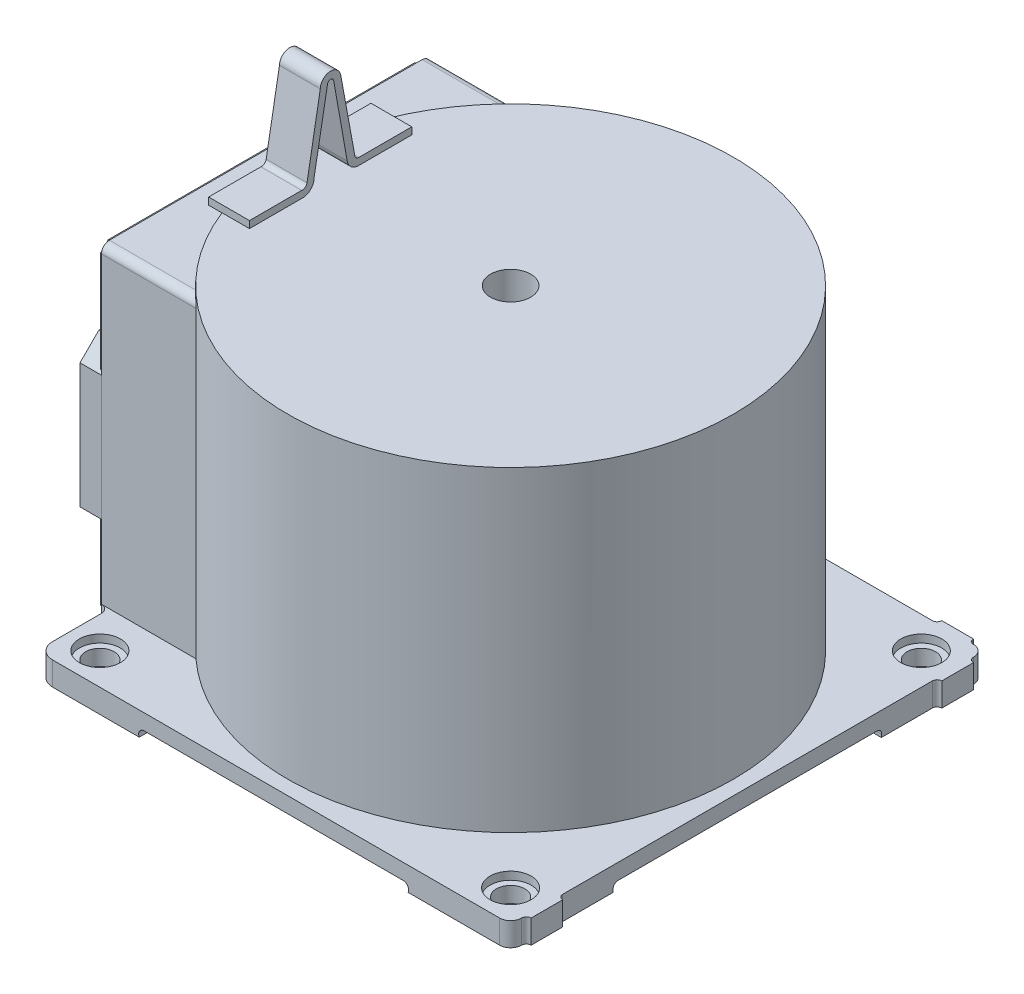
from build123d import *

# Parameters (mm, degrees)
BASE_EXTRUDE_DEPTH  = 14.9225
CUT_EXTRUDE1_DEPTH  = 304
CUT_EXTRUDE2_DEPTH  = 306
SKETCH7_R           = 13
CUT_EXTRUDE3_DEPTH  = 5
SKETCH8_R           = 9
CUT_EXTRUDE4_DEPTH  = 10.9225001
SKETCH9_R           = 141
BOSS_EXTRUDE1_DEPTH = 200.152
BOSS_EXTRUDE2_REACH = 310
BOSS_EXTRUDE3_DEPTH = 14.097
BOSS_EXTRUDE4_DEPTH = 2.667
BOSS_EXTRUDE5_DEPTH = 34.0995
SKETCH14_W          = 65
SKETCH14_H          = 35
SKETCH14_R          = 1.75
CUT_EXTRUDE5_DEPTH  = 17.272
BOSS_EXTRUDE6_DEPTH = 25.8445
SKETCH16_R          = 12.7
CUT_EXTRUDE6_DEPTH  = 216.0745001


with BuildPart() as part:
    # Sketch3 → Base-Extrude (new body)
    with BuildSketch(Plane(origin=(0, 0, 0), x_dir=(1, 0, 0), z_dir=(0, 1, 0))):
        with BuildLine():
            Line((140, 153), (120, 153))
            ThreePointArc((120, 153), (119.121320344, 150.878679656), (117, 150))
            Line((117, 150), (-117, 150))
            ThreePointArc((-117, 150), (-119.121320344, 150.878679656), (-120, 153))
            Line((-120, 153), (-140, 153))
            ThreePointArc((-140, 153), (-140.878679675, 150.878679658), (-143.000000024, 150))
            ThreePointArc((-143.000000024, 150), (-147.949747477, 147.94974746), (-150, 143))
            Line((-150, 143), (-150, 109))
            ThreePointArc((-150, 109), (-151.464466094, 105.464466094), (-155, 104))
            Line((-155, 104), (-155, -104))
            ThreePointArc((-155, -104), (-151.464466083, -105.464466088), (-149.999999983, -109))
            Line((-149.999999983, -109), (-149.999999983, -140))
            ThreePointArc((-149.999999983, -140), (-147.071067794, -147.071067812), (-139.999999983, -150))
            Line((-139.999999983, -150), (143.000000017, -150))
            ThreePointArc((143.000000017, -150), (147.949747486, -147.949747468), (150.000000017, -143))
            ThreePointArc((150.000000017, -143), (150.87867967, -140.87867966), (153.000000007, -140))
            Line((153.000000007, -140), (153.000000007, -120))
            ThreePointArc((153.000000007, -120), (150.878679659, -119.121320346), (150, -117))
            Line((150, -117), (150, 117))
            ThreePointArc((150, 117), (150.878679653, 119.12132034), (152.99999999, 120))
            Line((152.99999999, 120), (152.99999999, 140))
            ThreePointArc((152.99999999, 140), (150.87867965, 140.878679657), (150, 143))
            ThreePointArc((150, 143), (147.949747475, 147.949747475), (143, 150))
            ThreePointArc((143, 150), (140.878679653, 150.878679653), (140, 153))
        make_face()
    extrude(amount=BASE_EXTRUDE_DEPTH)

    # Sketch4 → Cut-Extrude1 (cut, through all)
    with BuildSketch(Plane.XY.offset(150)):
        with BuildLine():
            Line((82.000019446, 5), (-81.999980554, 5))
            ThreePointArc((-81.999980554, 5), (-84.938867255, 3.361421394), (-85.09, 0))
            Line((-85.09, 0), (-85.09, -16.51))
            Line((-85.09, -16.51), (85.09, -16.51))
            Line((85.09, -16.51), (85.09, 0))
            ThreePointArc((85.09, 0), (84.938895925, 3.361416251), (82.000019446, 5))
        make_face()
    extrude(amount=-CUT_EXTRUDE1_DEPTH, mode=Mode.SUBTRACT)

    # Sketch6 → Cut-Extrude2 (cut, through all)
    with BuildSketch(Plane(origin=(150, 0, 0), x_dir=(0, 0, -1), z_dir=(1, 0, 0))):
        with BuildLine():
            Line((82.00048999, 5.000122), (-82.00048001, 5.000122))
            ThreePointArc((-82.00048001, 5.000122), (-84.422201707, 3.861415448), (-85.09, 1.27))
            Line((-85.09, 1.27), (-85.09, -4.254424912))
            Line((-85.09, -4.254424912), (84.688287031, -4.254424912))
            Line((84.688287031, -4.254424912), (84.688287031, 1.855594301))
            ThreePointArc((84.688287031, 1.855594301), (84.068841228, 4.047086874), (82.00048999, 5.000122))
        make_face()
    extrude(amount=-CUT_EXTRUDE2_DEPTH, mode=Mode.SUBTRACT)

    # Sketch7 → Cut-Extrude3 (cut)
    with BuildSketch(Plane(origin=(0, 14.9225, 0), x_dir=(-1, 0, 0), z_dir=(0, 1, 0))):
        with Locations(Location((-130, 130, 0), (0, 0, 90))):  # turned: the seam where the file's is
            Circle(SKETCH7_R)
        with Locations(Location((-130, -130, 0), (0, 0, 90))):  # turned: the seam where the file's is
            Circle(SKETCH7_R)
        with Locations(Location((130, -130, 0), (0, 0, 90))):  # turned: the seam where the file's is
            Circle(SKETCH7_R)
        with Locations(Location((130, 130, 0), (0, 0, 90))):  # turned: the seam where the file's is
            Circle(SKETCH7_R)
    extrude(amount=-CUT_EXTRUDE3_DEPTH, mode=Mode.SUBTRACT)

    # Sketch8 → Cut-Extrude4 (cut, through all)
    with BuildSketch(Plane(origin=(0, 9.9225, 0), x_dir=(-1, 0, 0), z_dir=(0, 1, 0))):
        with Locations(Location((-130, -130, 0), (0, 0, 90))):  # turned: the seam where the file's is
            Circle(SKETCH8_R)
        with Locations(Location((130, -130, 0), (0, 0, 90))):  # turned: the seam where the file's is
            Circle(SKETCH8_R)
        with Locations(Location((130, 130, 0), (0, 0, 90))):  # turned: the seam where the file's is
            Circle(SKETCH8_R)
        with Locations(Location((-130, 130, 0), (0, 0, 90))):  # turned: the seam where the file's is
            Circle(SKETCH8_R)
    extrude(amount=-CUT_EXTRUDE4_DEPTH, mode=Mode.SUBTRACT)

    # Sketch9 → Boss-Extrude1 (add)
    with BuildSketch(Plane(origin=(0, 14.9225, 0), x_dir=(-1, 0, 0), z_dir=(0, 1, 0))):
        with Locations(Location((0, 0, 0), (0, 0, 312.473591148))):  # turned: the seam where the file's is
            Circle(SKETCH9_R)
    extrude(amount=BOSS_EXTRUDE1_DEPTH)

    # Sketch10 → Boss-Extrude2 (add, up to next)
    with BuildSketch(Plane.ZY.offset(155), mode=Mode.PRIVATE) as boss_extrude2_sk1:
        with BuildLine():
            Line((99.000000691, 211.999999309), (-99, 211.999999309))
            ThreePointArc((-99, 211.999999309), (-102.535533906, 210.535533215), (-104, 206.999999309))
            Line((-104, 206.999999309), (-104, 10))
            ThreePointArc((-104, 10), (-102.535533906, 6.464466094), (-99, 5))
            Line((-99, 5), (99, 5))
            ThreePointArc((99, 5), (102.535533906, 6.464466094), (104, 10))
            Line((104, 10), (104, 207))
            ThreePointArc((104, 207), (102.535534108, 210.535533417), (99.000000691, 211.999999309))
        make_face()
    boss_extrude2_tool1 = extrude(boss_extrude2_sk1.sketch, amount=-BOSS_EXTRUDE2_REACH, mode=Mode.PRIVATE) - part.part
    add(boss_extrude2_tool1.solids().sort_by_distance((-155, 108.5, 0))[0])

    # Sketch11 → Boss-Extrude3 (add)
    with BuildSketch(Plane.ZY.offset(155)):
        Polygon((91.5, 152), (12.5, 152), (0.5, 140), (0.5, 61), (12.5, 49), (91.5, 49), (103.5, 61), (103.5, 140), align=None)
    extrude(amount=BOSS_EXTRUDE3_DEPTH)

    # Sketch12 → Boss-Extrude4 (add)
    with BuildSketch(Plane.ZY.offset(155)):
        Polygon((-97, 210), (97, 210), (102, 205), (102, 12), (97, 7), (-77, 7), (-82, 12), (-82, 26), (-97, 26), (-102, 31), (-102, 205), align=None)
    extrude(amount=BOSS_EXTRUDE4_DEPTH)

    # Sketch13 → Boss-Extrude5 (add)
    with BuildSketch(Plane.ZY.offset(157.667)):
        with BuildLine():
            Line((-11.5, 119.00000157), (-11.5, 152.00000157))
            ThreePointArc((-11.5, 152.00000157), (-12.964466195, 155.535534927), (-16.500000017, 157))
            Line((-16.500000017, 157), (-79.500000017, 157))
            ThreePointArc((-79.500000017, 157), (-83.035533362, 155.53553446), (-84.5, 152.000001571))
            Line((-84.5, 152.000001571), (-84.5, 119.000001571))
            ThreePointArc((-84.5, 119.000001571), (-83.035534001, 115.46446711), (-79.5, 114))
            Line((-79.5, 114), (-16.5, 114))
            ThreePointArc((-16.5, 114), (-12.964465539, 115.464466649), (-11.5, 119.00000157))
        make_face()
        with BuildLine():
            Line((-79.500000017, 87.5), (-16.500000017, 87.5))
            ThreePointArc((-16.500000017, 87.5), (-12.96446666, 86.035534462), (-11.5, 82.50000157))
            Line((-11.5, 82.50000157), (-11.5, 49.50000157))
            ThreePointArc((-11.5, 49.50000157), (-12.964465999, 45.964467109), (-16.5, 44.5))
            Line((-16.5, 44.5), (-79.5, 44.5))
            ThreePointArc((-79.5, 44.5), (-83.035534461, 45.964466649), (-84.5, 49.500001571))
            Line((-84.5, 49.500001571), (-84.5, 82.500001571))
            ThreePointArc((-84.5, 82.500001571), (-83.035533362, 86.03553446), (-79.500000017, 87.5))
        make_face()
    extrude(amount=BOSS_EXTRUDE5_DEPTH)

    # Sketch14 → Cut-Extrude5 (cut)
    with BuildSketch(Plane.ZY.offset(191.7665)):
        with Locations((-48, 135.5)):
            Rectangle(SKETCH14_W, SKETCH14_H)
        with Locations((-61.5, 124.25)):
            Circle(SKETCH14_R, mode=Mode.SUBTRACT)
        with Locations((-57.0042, 124.25)):
            Circle(SKETCH14_R, mode=Mode.SUBTRACT)
        with Locations((-52.5084, 124.25)):
            Circle(SKETCH14_R, mode=Mode.SUBTRACT)
        with Locations((-48.0126, 124.25)):
            Circle(SKETCH14_R, mode=Mode.SUBTRACT)
        with Locations((-43.5168, 124.25)):
            Circle(SKETCH14_R, mode=Mode.SUBTRACT)
        with Locations((-39.021, 124.25)):
            Circle(SKETCH14_R, mode=Mode.SUBTRACT)
        with Locations((-34.5252, 124.25)):
            Circle(SKETCH14_R, mode=Mode.SUBTRACT)
        with Locations((-61.5, 128.7458)):
            Circle(SKETCH14_R, mode=Mode.SUBTRACT)
        with Locations((-57.0042, 128.7458)):
            Circle(SKETCH14_R, mode=Mode.SUBTRACT)
        with Locations((-52.5084, 128.7458)):
            Circle(SKETCH14_R, mode=Mode.SUBTRACT)
        with Locations((-48.0126, 128.7458)):
            Circle(SKETCH14_R, mode=Mode.SUBTRACT)
        with Locations((-43.5168, 128.7458)):
            Circle(SKETCH14_R, mode=Mode.SUBTRACT)
        with Locations((-39.021, 128.7458)):
            Circle(SKETCH14_R, mode=Mode.SUBTRACT)
        with Locations((-34.5252, 128.7458)):
            Circle(SKETCH14_R, mode=Mode.SUBTRACT)
        with Locations((-61.5, 133.2416)):
            Circle(SKETCH14_R, mode=Mode.SUBTRACT)
        with Locations((-57.0042, 133.2416)):
            Circle(SKETCH14_R, mode=Mode.SUBTRACT)
        with Locations((-52.5084, 133.2416)):
            Circle(SKETCH14_R, mode=Mode.SUBTRACT)
        with Locations((-48.0126, 133.2416)):
            Circle(SKETCH14_R, mode=Mode.SUBTRACT)
        with Locations((-43.5168, 133.2416)):
            Circle(SKETCH14_R, mode=Mode.SUBTRACT)
        with Locations((-39.021, 133.2416)):
            Circle(SKETCH14_R, mode=Mode.SUBTRACT)
        with Locations((-34.5252, 133.2416)):
            Circle(SKETCH14_R, mode=Mode.SUBTRACT)
        with Locations((-61.5, 137.7374)):
            Circle(SKETCH14_R, mode=Mode.SUBTRACT)
        with Locations((-57.0042, 137.7374)):
            Circle(SKETCH14_R, mode=Mode.SUBTRACT)
        with Locations((-52.5084, 137.7374)):
            Circle(SKETCH14_R, mode=Mode.SUBTRACT)
        with Locations((-48.0126, 137.7374)):
            Circle(SKETCH14_R, mode=Mode.SUBTRACT)
        with Locations((-43.5168, 137.7374)):
            Circle(SKETCH14_R, mode=Mode.SUBTRACT)
        with Locations((-39.021, 137.7374)):
            Circle(SKETCH14_R, mode=Mode.SUBTRACT)
        with Locations((-34.5252, 137.7374)):
            Circle(SKETCH14_R, mode=Mode.SUBTRACT)
        with Locations((-61.5, 142.2332)):
            Circle(SKETCH14_R, mode=Mode.SUBTRACT)
        with Locations((-57.0042, 142.2332)):
            Circle(SKETCH14_R, mode=Mode.SUBTRACT)
        with Locations((-52.5084, 142.2332)):
            Circle(SKETCH14_R, mode=Mode.SUBTRACT)
        with Locations((-48.0126, 142.2332)):
            Circle(SKETCH14_R, mode=Mode.SUBTRACT)
        with Locations((-43.5168, 142.2332)):
            Circle(SKETCH14_R, mode=Mode.SUBTRACT)
        with Locations((-39.021, 142.2332)):
            Circle(SKETCH14_R, mode=Mode.SUBTRACT)
        with Locations((-34.5252, 142.2332)):
            Circle(SKETCH14_R, mode=Mode.SUBTRACT)
        with Locations((-61.5, 146.729)):
            Circle(SKETCH14_R, mode=Mode.SUBTRACT)
        with Locations((-57.0042, 146.729)):
            Circle(SKETCH14_R, mode=Mode.SUBTRACT)
        with Locations((-52.5084, 146.729)):
            Circle(SKETCH14_R, mode=Mode.SUBTRACT)
        with Locations((-48.0126, 146.729)):
            Circle(SKETCH14_R, mode=Mode.SUBTRACT)
        with Locations((-43.5168, 146.729)):
            Circle(SKETCH14_R, mode=Mode.SUBTRACT)
        with Locations((-39.021, 146.729)):
            Circle(SKETCH14_R, mode=Mode.SUBTRACT)
        with Locations((-34.5252, 146.729)):
            Circle(SKETCH14_R, mode=Mode.SUBTRACT)
        with Locations((-48, 66)):
            Rectangle(SKETCH14_W, SKETCH14_H)
        with Locations((-61.5, 54.75)):
            Circle(SKETCH14_R, mode=Mode.SUBTRACT)
        with Locations((-57.0042, 54.75)):
            Circle(SKETCH14_R, mode=Mode.SUBTRACT)
        with Locations((-52.5084, 54.75)):
            Circle(SKETCH14_R, mode=Mode.SUBTRACT)
        with Locations((-48.0126, 54.75)):
            Circle(SKETCH14_R, mode=Mode.SUBTRACT)
        with Locations((-43.5168, 54.75)):
            Circle(SKETCH14_R, mode=Mode.SUBTRACT)
        with Locations((-39.021, 54.75)):
            Circle(SKETCH14_R, mode=Mode.SUBTRACT)
        with Locations((-34.5252, 54.75)):
            Circle(SKETCH14_R, mode=Mode.SUBTRACT)
        with Locations((-61.5, 59.2458)):
            Circle(SKETCH14_R, mode=Mode.SUBTRACT)
        with Locations((-57.0042, 59.2458)):
            Circle(SKETCH14_R, mode=Mode.SUBTRACT)
        with Locations((-52.5084, 59.2458)):
            Circle(SKETCH14_R, mode=Mode.SUBTRACT)
        with Locations((-48.0126, 59.2458)):
            Circle(SKETCH14_R, mode=Mode.SUBTRACT)
        with Locations((-43.5168, 59.2458)):
            Circle(SKETCH14_R, mode=Mode.SUBTRACT)
        with Locations((-39.021, 59.2458)):
            Circle(SKETCH14_R, mode=Mode.SUBTRACT)
        with Locations((-34.5252, 59.2458)):
            Circle(SKETCH14_R, mode=Mode.SUBTRACT)
        with Locations((-61.5, 63.7416)):
            Circle(SKETCH14_R, mode=Mode.SUBTRACT)
        with Locations((-57.0042, 63.7416)):
            Circle(SKETCH14_R, mode=Mode.SUBTRACT)
        with Locations((-52.5084, 63.7416)):
            Circle(SKETCH14_R, mode=Mode.SUBTRACT)
        with Locations((-48.0126, 63.7416)):
            Circle(SKETCH14_R, mode=Mode.SUBTRACT)
        with Locations((-43.5168, 63.7416)):
            Circle(SKETCH14_R, mode=Mode.SUBTRACT)
        with Locations((-39.021, 63.7416)):
            Circle(SKETCH14_R, mode=Mode.SUBTRACT)
        with Locations((-34.5252, 63.7416)):
            Circle(SKETCH14_R, mode=Mode.SUBTRACT)
        with Locations((-61.5, 68.2374)):
            Circle(SKETCH14_R, mode=Mode.SUBTRACT)
        with Locations((-57.0042, 68.2374)):
            Circle(SKETCH14_R, mode=Mode.SUBTRACT)
        with Locations((-52.5084, 68.2374)):
            Circle(SKETCH14_R, mode=Mode.SUBTRACT)
        with Locations((-48.0126, 68.2374)):
            Circle(SKETCH14_R, mode=Mode.SUBTRACT)
        with Locations((-43.5168, 68.2374)):
            Circle(SKETCH14_R, mode=Mode.SUBTRACT)
        with Locations((-39.021, 68.2374)):
            Circle(SKETCH14_R, mode=Mode.SUBTRACT)
        with Locations((-34.5252, 68.2374)):
            Circle(SKETCH14_R, mode=Mode.SUBTRACT)
        with Locations((-61.5, 72.7332)):
            Circle(SKETCH14_R, mode=Mode.SUBTRACT)
        with Locations((-57.0042, 72.7332)):
            Circle(SKETCH14_R, mode=Mode.SUBTRACT)
        with Locations((-52.5084, 72.7332)):
            Circle(SKETCH14_R, mode=Mode.SUBTRACT)
        with Locations((-48.0126, 72.7332)):
            Circle(SKETCH14_R, mode=Mode.SUBTRACT)
        with Locations((-43.5168, 72.7332)):
            Circle(SKETCH14_R, mode=Mode.SUBTRACT)
        with Locations((-39.021, 72.7332)):
            Circle(SKETCH14_R, mode=Mode.SUBTRACT)
        with Locations((-34.5252, 72.7332)):
            Circle(SKETCH14_R, mode=Mode.SUBTRACT)
        with Locations((-61.5, 77.229)):
            Circle(SKETCH14_R, mode=Mode.SUBTRACT)
        with Locations((-57.0042, 77.229)):
            Circle(SKETCH14_R, mode=Mode.SUBTRACT)
        with Locations((-52.5084, 77.229)):
            Circle(SKETCH14_R, mode=Mode.SUBTRACT)
        with Locations((-48.0126, 77.229)):
            Circle(SKETCH14_R, mode=Mode.SUBTRACT)
        with Locations((-43.5168, 77.229)):
            Circle(SKETCH14_R, mode=Mode.SUBTRACT)
        with Locations((-39.021, 77.229)):
            Circle(SKETCH14_R, mode=Mode.SUBTRACT)
        with Locations((-34.5252, 77.229)):
            Circle(SKETCH14_R, mode=Mode.SUBTRACT)
    extrude(amount=-CUT_EXTRUDE5_DEPTH, mode=Mode.SUBTRACT)

    # Sketch15 → Boss-Extrude6 (add)
    with BuildSketch(Plane(origin=(-139.785529716, 0, 0), x_dir=(0, 0, -1), z_dir=(1, 0, 0))):
        with BuildLine():
            Line((51.38765, 215), (51.38765, 219.5))
            Line((51.38765, 219.5), (17.8926, 219.5))
            ThreePointArc((17.8926, 219.5), (15.982182064, 220.311570459), (15.24, 222.25))
            Line((15.24, 222.25), (6.401250395, 270.394371155))
            ThreePointArc((6.401250395, 270.394371155), (-0.608765334, 275.714829121), (-6.542832254, 269.216025902))
            Line((-6.542832254, 269.216025902), (-14.938176741, 221.979055467))
            ThreePointArc((-14.938176741, 221.979055467), (-16.126165069, 220.067096128), (-18.304537572, 219.5))
            Line((-18.304537572, 219.5), (-51.38766, 219.5))
            Line((-51.38766, 219.5), (-51.38766, 215))
            Line((-51.38766, 215), (-36.917247145, 215))
            Line((-36.917247145, 215), (-36.917247145, 213.335962382))
            Line((-36.917247145, 213.335962382), (-31.522258863, 213.335962382))
            Line((-31.522258863, 213.335962382), (-31.522258863, 215))
            Line((-31.522258863, 215), (-17.8926, 215))
            ThreePointArc((-17.8926, 215), (-12.642933448, 217.174483084), (-10.468450364, 222.424149636))
            Line((-10.468450364, 222.424149636), (-1.969615506, 269.612954355))
            ThreePointArc((-1.969615506, 269.612954355), (-0.018702678, 271.24157243), (1.927643115, 269.60749907))
            Line((1.927643115, 269.60749907), (10.506541852, 221.197638667))
            ThreePointArc((10.506541852, 221.197638667), (13.075674104, 216.754392167), (17.899053429, 215))
            Line((17.899053429, 215), (51.38765, 215))
        make_face()
    extrude(amount=BOSS_EXTRUDE6_DEPTH)

    # Sketch16 → Cut-Extrude6 (cut, through all)
    with BuildSketch(Plane(origin=(0, 215.0745, 0), x_dir=(-1, 0, 0), z_dir=(0, 1, 0))):
        with Locations(Location((0, 0, 0), (0, 0, 90))):  # turned: the seam where the file's is
            Circle(SKETCH16_R)
    extrude(amount=-CUT_EXTRUDE6_DEPTH, mode=Mode.SUBTRACT)


solid = part.part
